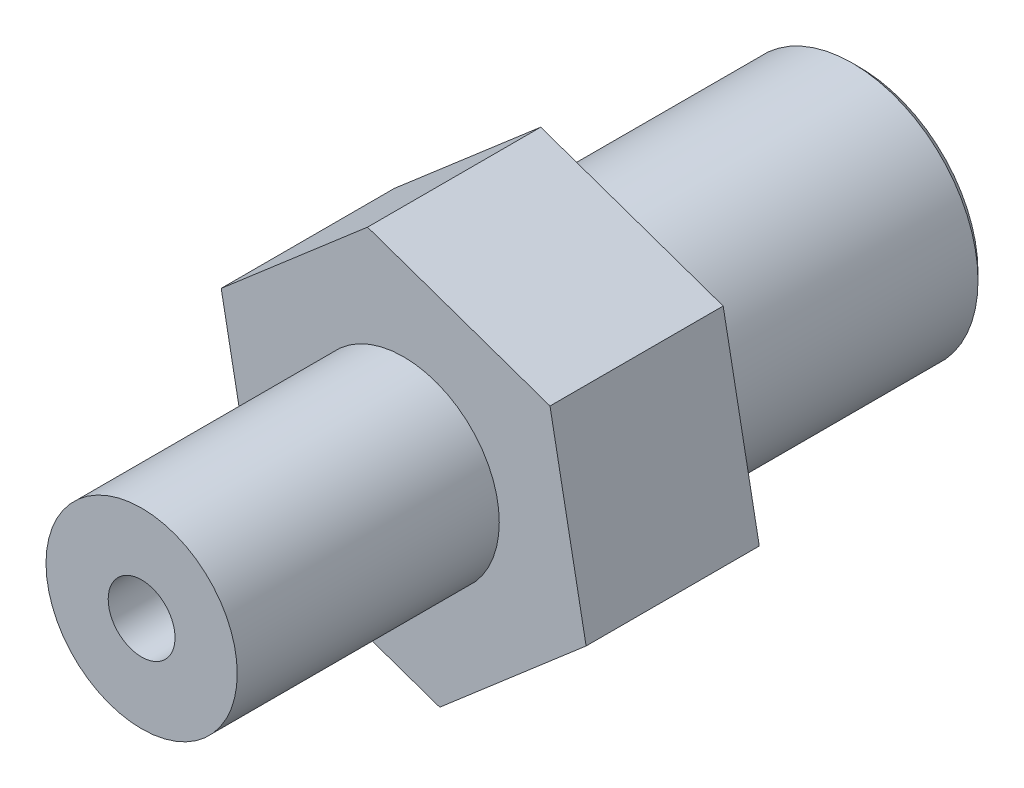
from build123d import *

# Parameters (mm, degrees)
SALIENTE_EXTRUIR1_DEPTH = 5.75
CROQUIS3_R              = 3.175
SALIENTE_EXTRUIR2_DEPTH = 8.7
CROQUIS5_R              = 4.17
SALIENTE_EXTRUIR3_DEPTH = 9.4
CROQUIS6_R              = 1.11
CORTAR_EXTRUIR1_DEPTH   = 24.85
CHAFL_N1_SIZE           = 0.25


with BuildPart() as part:
    # Croquis2 → Saliente-Extruir1 (new body)
    with BuildSketch(Plane.XY):
        Polygon((4.859109949, 4.189463282), (-1.198626656, 6.302844296), (-6.057736605, 2.113381014), (-4.859109949, -4.189463282), (1.198626656, -6.302844296), (6.057736605, -2.113381014), align=None)
    extrude(amount=SALIENTE_EXTRUIR1_DEPTH)

    # Croquis3 → Saliente-Extruir2 (add)
    with BuildSketch(Plane.XY.offset(5.75)):
        Circle(CROQUIS3_R)
    extrude(amount=SALIENTE_EXTRUIR2_DEPTH)

    # Croquis5 → Saliente-Extruir3 (add)
    with BuildSketch(Plane(origin=(0, 0, 0), x_dir=(-1, 0, 0), z_dir=(0, 0, -1))):
        Circle(CROQUIS5_R)
    extrude(amount=SALIENTE_EXTRUIR3_DEPTH)

    # Croquis6 → Cortar-Extruir1 (cut, through all)
    with BuildSketch(Plane(origin=(0, 0, -9.4), x_dir=(-1, 0, 0), z_dir=(0, 0, -1))):
        Circle(CROQUIS6_R)
    extrude(amount=-CORTAR_EXTRUIR1_DEPTH, mode=Mode.SUBTRACT)

    # Chaflán1
    chafl_n1_edges = [part.edges().sort_by_distance(p)[0] for p in [
        (4.17, 0, 0),
        (4.17, 0, -9.4),
        (1.11, 0, -9.4),
    ]]
    chamfer(chafl_n1_edges, length=CHAFL_N1_SIZE)


solid = part.part
